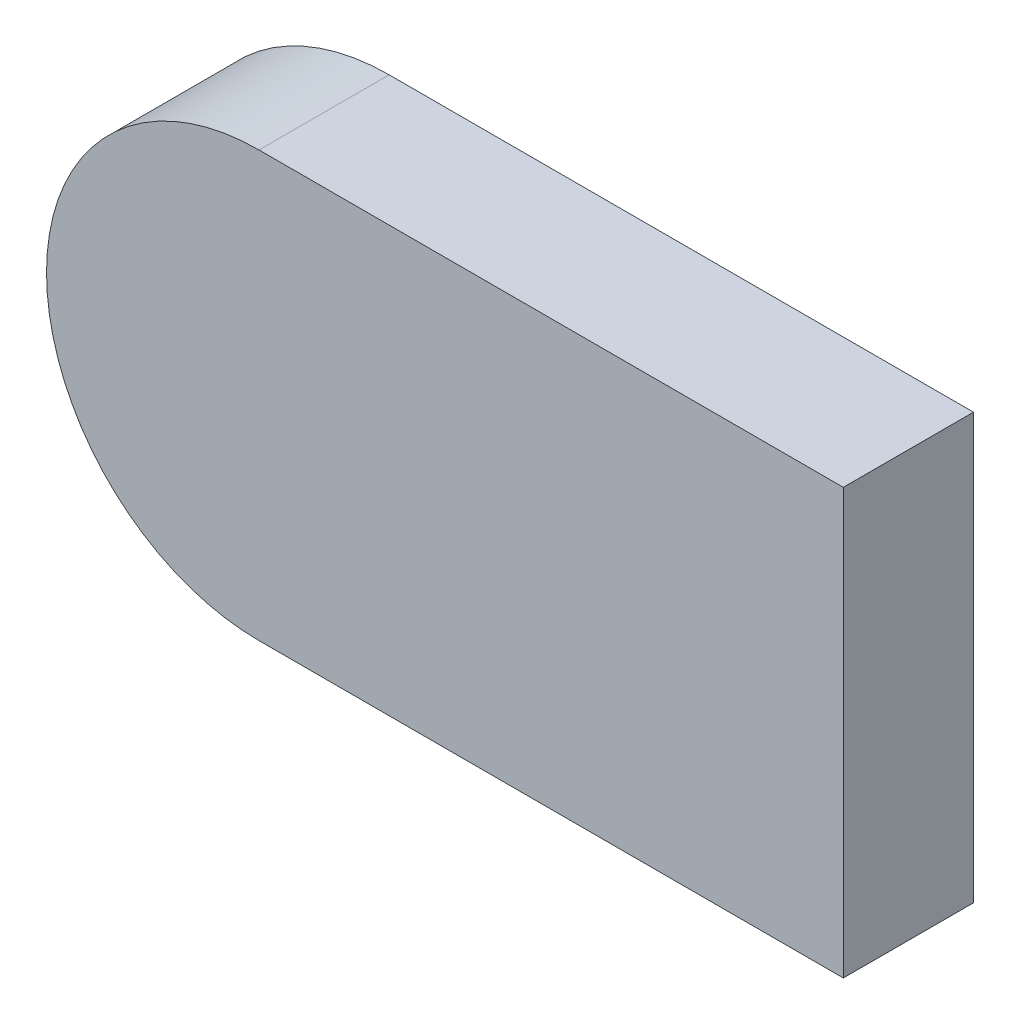
from build123d import *

# Parameters (mm, degrees)
BOSS_EXTRUDE1_DEPTH = 49


with BuildPart() as part:
    # Sketch1 → Boss-Extrude1 (new body)
    with BuildSketch(Plane.XY):
        with BuildLine():
            ThreePointArc((-41.624123865, -90.81860883), (80, -22.5), (-41.624123865, 45.81860883))
            ThreePointArc((-41.624123865, 45.81860883), (-80, -22.5), (-41.624123865, -90.81860883))
        make_face()
        with BuildLine():
            Line((220, -102.5), (220, 57.5))
            Line((220, 57.5), (0, 57.5))
            ThreePointArc((0, 57.5), (80, -22.5), (0, -102.5))
            Line((0, -102.5), (220, -102.5))
        make_face()
    extrude(amount=-BOSS_EXTRUDE1_DEPTH)


solid = part.part
